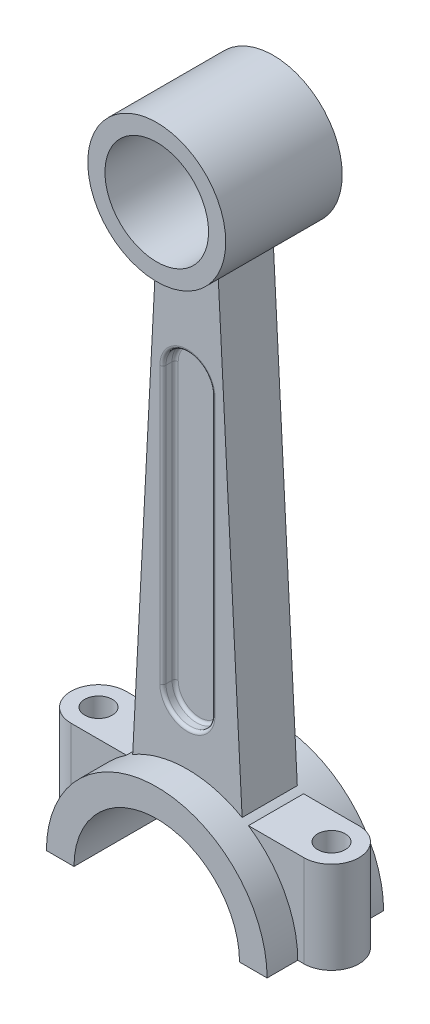
from build123d import *

# Parameters (mm, degrees)
SKETCH1_R             = 22.5
SKETCH1_R_2           = 16.9
BOSS_EXTRUDE1_DEPTH   = 19
BOSS_EXTRUDE1_2_DEPTH = 19
BOSS_EXTRUDE2_DEPTH   = 9
CUT_EXTRUDE1_DEPTH    = 4
FILLET1_R             = 1
BOSS_EXTRUDE3_DEPTH   = 30
CUT_EXTRUDE2_DEPTH    = 29
SKETCH5_R             = 4.5
CUT_EXTRUDE3_DEPTH    = 31


with BuildPart() as part:
    # Sketch1 → Boss-Extrude1 (new body, symmetric)
    with BuildSketch(Plane.XY):
        Circle(SKETCH1_R)
        Circle(SKETCH1_R_2, mode=Mode.SUBTRACT)
    extrude(amount=BOSS_EXTRUDE1_DEPTH, both=True)


with BuildPart() as body_2:
    # Sketch1 → Boss-Extrude1 2 (new body, symmetric)
    with BuildSketch(Plane.XY):
        with BuildLine():
            ThreePointArc((36, -201.2), (0, -165.2), (-36, -201.2))
            Line((-36, -201.2), (-27, -201.2))
            ThreePointArc((-27, -201.2), (0, -174.2), (27, -201.2))
            Line((27, -201.2), (36, -201.2))
        make_face()
    extrude(amount=BOSS_EXTRUDE1_2_DEPTH, both=True)

    # Sketch3 → Boss-Extrude3 (add)
    with BuildSketch(Plane(origin=(0, -171.2, 0), x_dir=(-1, 0, 0), z_dir=(0, -1, 0))):
        with BuildLine():
            Line((38, -9), (-38, -9))
            ThreePointArc((-38, -9), (-47, 0), (-38, 9))
            Line((-38, 9), (38, 9))
            ThreePointArc((38, 9), (47, 0), (38, -9))
        make_face()
    extrude(amount=BOSS_EXTRUDE3_DEPTH)

    # Sketch4 → Cut-Extrude2 (cut, through all)
    with BuildSketch(Plane.XY.offset(9)):
        with BuildLine():
            Line((-27, -201.2), (27, -201.2))
            ThreePointArc((27, -201.2), (0, -174.2), (-27, -201.2))
        make_face()
    extrude(amount=-CUT_EXTRUDE2_DEPTH, mode=Mode.SUBTRACT)

    # Sketch5 → Cut-Extrude3 (cut, through all)
    with BuildSketch(Plane(origin=(0, -171.2, 0), x_dir=(1, 0, 0), z_dir=(0, 1, 0))):
        with Locations((38, 0)):
            Circle(SKETCH5_R)
        with Locations((-38, 0)):
            Circle(SKETCH5_R)
    extrude(amount=-CUT_EXTRUDE3_DEPTH, mode=Mode.SUBTRACT)


with BuildPart() as body_3:
    # Sketch1_5 → Boss-Extrude2 (new body, symmetric)
    with BuildSketch(Plane.XY):
        with BuildLine():
            ThreePointArc((10, -20.155644371), (0, -22.5), (-10, -20.155644371))
            Line((-10, -20.155644371), (-17.849697213, -169.936789841))
            ThreePointArc((-17.849697213, -169.936789841), (0, -165.2), (17.849697213, -169.936789841))
            Line((17.849697213, -169.936789841), (10, -20.155644371))
        make_face()
    extrude(amount=BOSS_EXTRUDE2_DEPTH, both=True)

    # Sketch2 → Cut-Extrude1 (cut)
    with BuildSketch(Plane.XY.offset(9)):
        with BuildLine():
            Line((-8, -145.6), (-8, -55.6))
            ThreePointArc((-8, -55.6), (0, -47.6), (8, -55.6))
            Line((8, -55.6), (8, -145.6))
            ThreePointArc((8, -145.6), (0, -153.6), (-8, -145.6))
        make_face()
    cut_extrude1 = extrude(amount=-CUT_EXTRUDE1_DEPTH, mode=Mode.SUBTRACT)

    # Mirror1: Cut-Extrude1 across plane
    add(cut_extrude1.mirror(Plane.XY), mode=Mode.SUBTRACT)

    # Fillet1
    fillet1_edges = [body_3.edges().sort_by_distance(p)[0] for p in [
        (0, -153.6, 5),
        (-8, -100.6, 5),
        (0, -47.6, 5),
        (8, -100.6, 5),
        (0, -153.6, 9),
        (8, -100.6, 9),
        (0, -47.6, 9),
        (-8, -100.6, 9),
        (0, -153.6, -9),
        (8, -100.6, -9),
        (0, -47.6, -9),
        (-8, -100.6, -9),
        (0, -153.6, -5),
        (8, -100.6, -5),
        (0, -47.6, -5),
        (-8, -100.6, -5),
    ]]
    fillet(fillet1_edges, radius=FILLET1_R)


solid = Compound([part.part, body_2.part, body_3.part])
